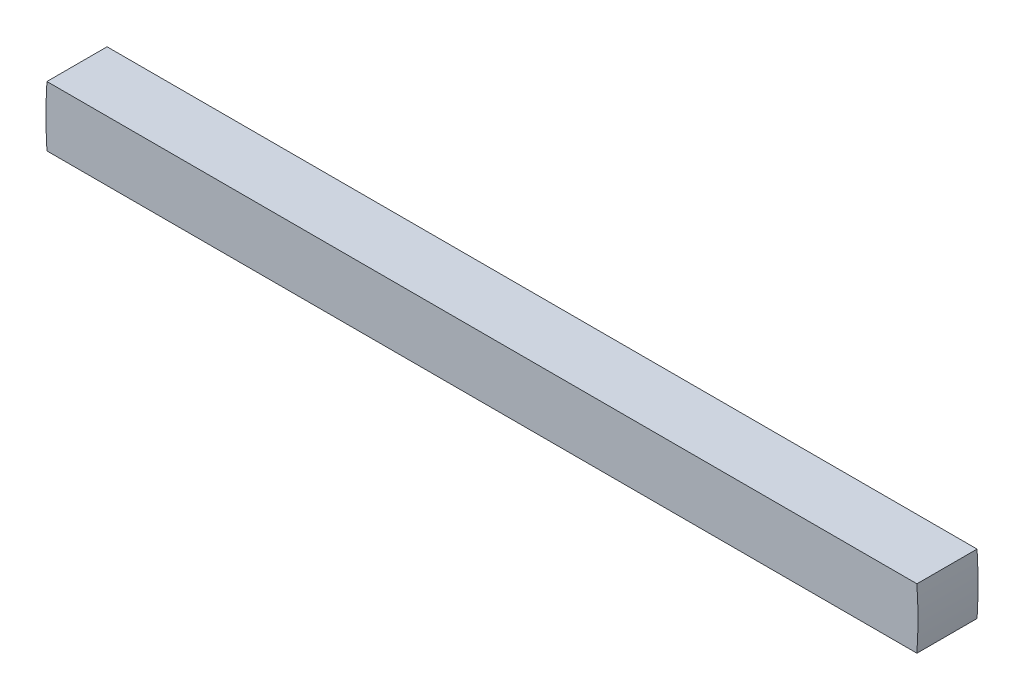
from build123d import *

# Parameters (mm, degrees)
BOSS_EXTRUDE1_DEPTH = 5.13588
SKETCH2_R           = 19.84375
CUT_EXTRUDE1_DEPTH  = 1.96088
SKETCH4_W           = 53.14157338
SKETCH4_H           = 10.064691928
CUT_EXTRUDE3_DEPTH  = 4.175


with BuildPart() as part:
    # Sketch1 → Boss-Extrude1 (new body)
    with BuildSketch(Plane.XY):
        with BuildLine():
            Line((-22.963943375, -1.5875), (22.963943375, -1.5875))
            ThreePointArc((22.963943375, -1.5875), (23.01875, 0), (22.963943375, 1.5875))
            Line((22.963943375, 1.5875), (-22.963943375, 1.5875))
            ThreePointArc((-22.963943375, 1.5875), (-23.01875, 0), (-22.963943375, -1.5875))
        make_face()
    extrude(amount=BOSS_EXTRUDE1_DEPTH)

    # Sketch2 → Cut-Extrude1 (cut)
    with BuildSketch(Plane.XY.offset(5.13588)):
        Circle(SKETCH2_R)
    extrude(amount=-CUT_EXTRUDE1_DEPTH, mode=Mode.SUBTRACT)

    # Sketch4 → Cut-Extrude3 (cut, through all)
    with BuildSketch(Plane(origin=(0, 1.5875, 0), x_dir=(1, 0, 0), z_dir=(0, 1, 0))):
        with Locations((-0.065706256, -8.207345964)):
            Rectangle(SKETCH4_W, SKETCH4_H)
    extrude(amount=-CUT_EXTRUDE3_DEPTH, mode=Mode.SUBTRACT)


solid = part.part
